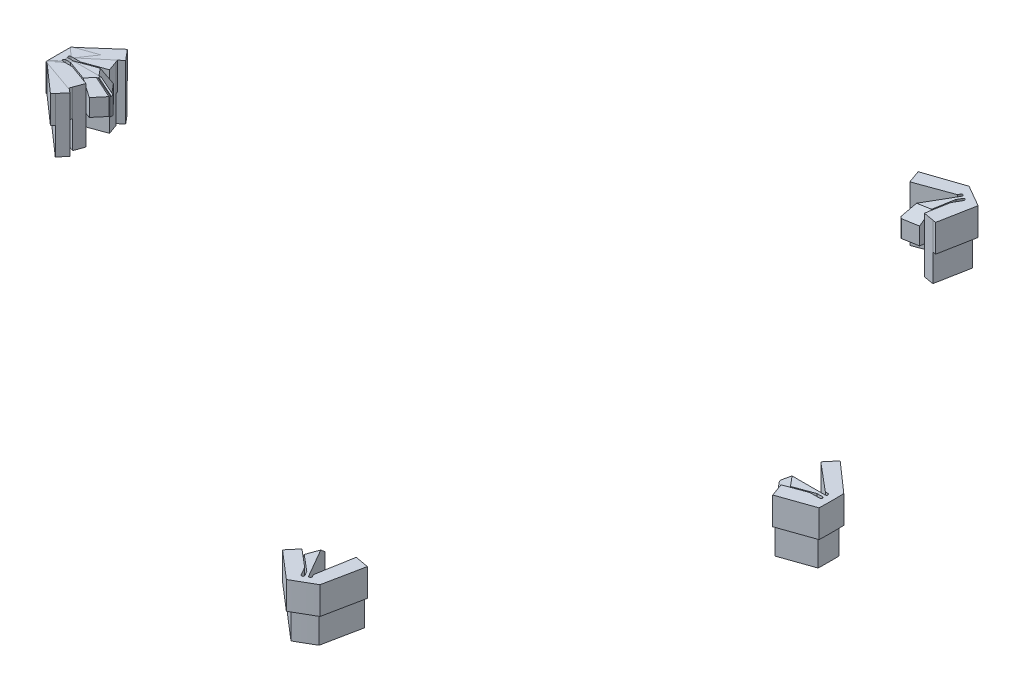
from build123d import *

# Parameters (mm, degrees)
EXTRUDE_1_DEPTH          = 8
EXTRUDE_2_DEPTH          = 8
EXTRUDE_2_DEPTH_BACK     = 8
CUT_EXTRUDE_1_REACH      = 118.005
SKETCH_10_W              = 8
SKETCH_10_H              = 1
PATTERN_CIRCULAR_1_COUNT = 3


with BuildPart() as part:
    # 草图1 → 凸台-拉伸1 (new body)
    with BuildSketch(Plane(origin=(0, 0, 0), x_dir=(1, 0, 0), z_dir=(0, 1, 0))):
        Polygon((97, 0), (99.938655786, -3.50215359), (108.461752725, -0.4), (109.560743693, -0.4), (110.360743693, -0.4), (110.360743693, 0.4), (109.560743693, 0.4), (97, 0.4), align=None)
    extrude(amount=EXTRUDE_1_DEPTH)

    # 草图2 → 凸台-拉伸2 (add, two sides: drawn at the far end of the back side and taken through both)
    with BuildSketch(Plane(origin=(0, 0, 0), x_dir=(1, 0, 0), z_dir=(0, 1, 0)).offset(-EXTRUDE_2_DEPTH_BACK)):
        with BuildLine():
            Line((100.980954449, 8.113083093), (109.219646061, 1.2))
            Line((109.219646061, 1.2), (109.960743693, 1.2))
            ThreePointArc((109.960743693, 1.2), (110.360743693, 0.8), (109.960743693, 0.4))
            Line((109.960743693, 0.4), (110.360743693, 0.4))
            Line((110.360743693, 0.4), (110.360743693, -0.4))
            Line((110.360743693, -0.4), (109.960743693, -0.4))
            ThreePointArc((109.960743693, -0.4), (110.360743693, -0.8), (109.960743693, -1.2))
            Line((109.960743693, -1.2), (107.14091211, -1.2))
            Line((107.14091211, -1.2), (100.980954449, -3.442041233))
            Line((100.980954449, -3.442041233), (102.007014879, -6.261119095))
            Line((102.007014879, -6.261119095), (111.32033448, -2.999727837))
            ThreePointArc((111.32033448, -2.999727837), (111.360743693, 0), (111.32033448, 2.999727837))
            Line((111.32033448, 2.999727837), (102.909317278, 10.411216422))
            Line((102.909317278, 10.411216422), (100.980954449, 8.113083093))
        make_face()
    extrude(amount=EXTRUDE_2_DEPTH + EXTRUDE_2_DEPTH_BACK)

    # 切除-拉伸1: up to this plane
    cut_extrude_1_end = Plane(origin=(97, 8, -0.4), z_dir=(0, 0, 1))
    # 草图4 → 切除-拉伸1 (cut, up to the surface)
    with BuildSketch(Plane(origin=(12.816172402, 0, 35.212144277), x_dir=(0.9396926207859105, 0, -0.34202014332566305), z_dir=(0.34202014332566305, 0, 0.9396926207859105)), mode=Mode.PRIVATE) as cut_extrude_1_sk1:
        Polygon((92.7138103, 5), (95.7138103, 8), (92.7138103, 8), align=None)
    cut_extrude_1_tool1 = split(extrude(cut_extrude_1_sk1.sketch, amount=CUT_EXTRUDE_1_REACH, dir=(-0.642787609687, 0, -0.766044443119), mode=Mode.PRIVATE), bisect_by=cut_extrude_1_end, keep=Keep.BOTH, mode=Mode.PRIVATE)
    add(cut_extrude_1_tool1.solids().sort_by_distance((100.878348, 7, 3.160133))[0], mode=Mode.SUBTRACT)

    # 扫描1: sweep along a path in 草图11
    with BuildLine(Plane(origin=(0, 0, 0), x_dir=(1, 0, 0), z_dir=(0, 1, 0))) as sweep_1_path:
        Line((102.909317278, 10.411216422), (111.32033448, 2.999727837))
        ThreePointArc((111.32033448, 2.999727837), (111.360743693, 0), (111.32033448, -2.999727837))
        Line((111.32033448, -2.999727837), (102.007014879, -6.261119095))
    # 草图10 → 扫描1 (sweep)
    with BuildSketch(Plane(origin=(88.911269928, 0, -31.135454481), x_dir=(0, 1, 0), z_dir=(0.9438036980303652, 0, -0.33050654998684587))):
        with Locations((4, 40.123253918)):
            Rectangle(SKETCH_10_W, SKETCH_10_H)
    sweep(path=sweep_1_path.line, transition=Transition.RIGHT)


with BuildPart() as body_2:
    # 镜向3: mirrored copy
    add(part.part.mirror(Plane(origin=(0, 0, 0), x_dir=(0, 0, 1), z_dir=(1, 0, 0))))


with BuildPart() as body_3:
    # 镜向4: mirrored copy
    add(body_2.part.mirror(Plane.XY))


with BuildPart() as pattern_circular_1_1:
    # 阵列(圆周)1: pattern copy
    add(body_3.part.rotate(Axis((0, 0, 0), (0, 1, 0)), 1 * 360 / PATTERN_CIRCULAR_1_COUNT))


with BuildPart() as pattern_circular_1_2:
    # 阵列(圆周)1: pattern copy
    add(body_3.part.rotate(Axis((0, 0, 0), (0, 1, 0)), 2 * 360 / PATTERN_CIRCULAR_1_COUNT))


solid = Compound([part.part, body_2.part, body_3.part, pattern_circular_1_1.part, pattern_circular_1_2.part])
